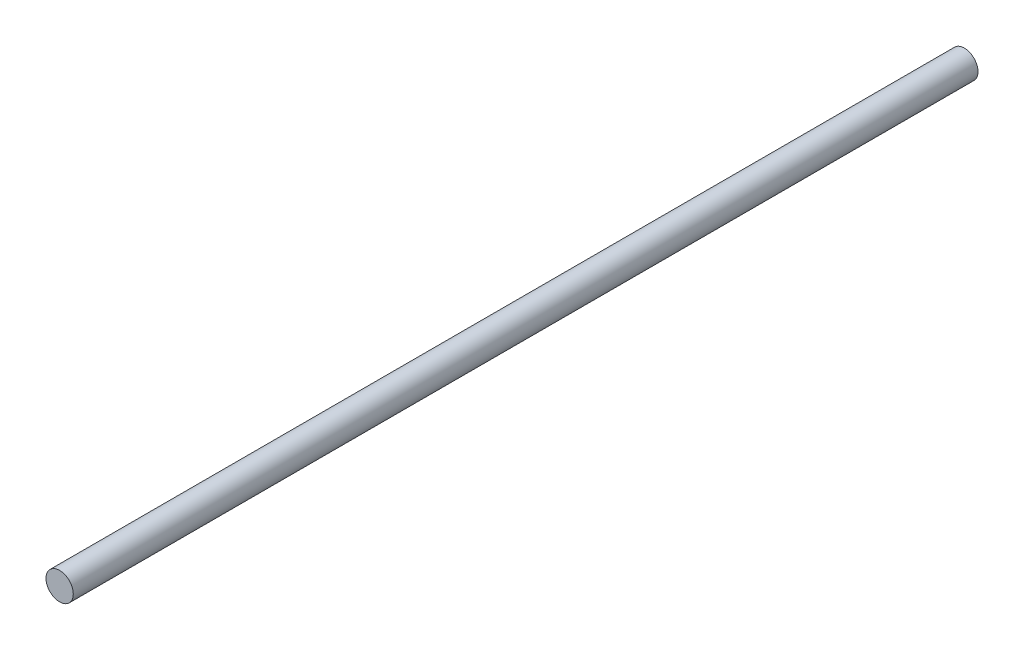
from build123d import *

# Parameters (mm, degrees)
SKETCH1_R           = 3.175
BOSS_EXTRUDE1_DEPTH = 210.3628


with BuildPart() as part:
    # Sketch1 → Boss-Extrude1 (new body)
    with BuildSketch(Plane.XY):
        Circle(SKETCH1_R)
    extrude(amount=BOSS_EXTRUDE1_DEPTH)


solid = part.part
